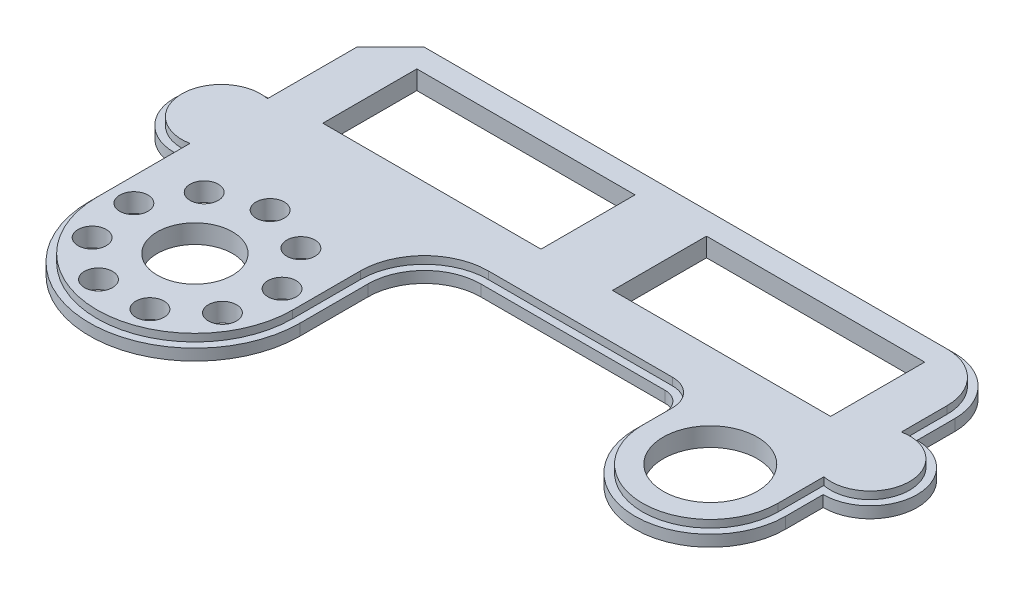
from build123d import *

# Parameters (mm, degrees)
SKETCH1_R           = 15.875
SKETCH1_R_2         = 12.7
SKETCH1_W           = 73.66
SKETCH1_H           = 31.75
BOSS_EXTRUDE2_DEPTH = 6.35
CUT_EXTRUDE1_DEPTH  = 2.54
SKETCH3_R           = 4.7625
CUT_EXTRUDE2_DEPTH  = 7.35
CIRPATTERN1_COUNT   = 9


with BuildPart() as part:
    # Sketch1 → Boss-Extrude2 (new body)
    with BuildSketch(Plane(origin=(0, 0, 0), x_dir=(1, 0, 0), z_dir=(0, 1, 0))):
        with Locations((209.55, -47.625)):
            Circle(SKETCH1_R)
        with Locations((0, -57.15)):
            Circle(SKETCH1_R)
        with BuildLine():
            Line((209.55, -76.2), (209.55, -19.05))
            ThreePointArc((209.55, -19.05), (203.970384182, -5.579615818), (190.5, 0))
            Line((190.5, 0), (12.7, 0))
            Line((12.7, 0), (0, -12.7))
            Line((0, -12.7), (0, -101.6))
            ThreePointArc((0, -101.6), (35.56, -137.16), (71.12, -101.6))
            Line((71.12, -101.6), (71.12, -78.74))
            ThreePointArc((71.12, -78.74), (76.699615818, -65.269615818), (90.17, -59.69))
            Line((90.17, -59.69), (152.4, -59.69))
            ThreePointArc((152.4, -59.69), (156.890128061, -61.549871939), (158.75, -66.04))
            Line((158.75, -66.04), (158.75, -76.2))
            ThreePointArc((158.75, -76.2), (184.15, -101.6), (209.55, -76.2))
        make_face()
        with Locations((35.56, -101.6)):
            Circle(SKETCH1_R_2, mode=Mode.SUBTRACT)
        with Locations((184.15, -76.2)):
            Circle(SKETCH1_R, mode=Mode.SUBTRACT)
        with Locations((153.67, -26.035)):
            Rectangle(SKETCH1_W, SKETCH1_H, mode=Mode.SUBTRACT)
        with Locations((55.88, -26.035)):
            Rectangle(SKETCH1_W, SKETCH1_H, mode=Mode.SUBTRACT)
        with BuildLine():
            ThreePointArc((15.875, -57.15), (11.225320151, -45.924679849), (0, -41.275))
            Line((0, -41.275), (0, -73.025))
            ThreePointArc((0, -73.025), (11.225320151, -68.375320151), (15.875, -57.15))
        make_face()
        with BuildLine():
            Line((0, -73.025), (0, -41.275))
            ThreePointArc((0, -41.275), (-15.875, -57.15), (0, -73.025))
        make_face()
        with BuildLine():
            ThreePointArc((15.875, -57.15), (11.225320151, -45.924679849), (0, -41.275))
            Line((0, -41.275), (0, -73.025))
            ThreePointArc((0, -73.025), (11.225320151, -68.375320151), (15.875, -57.15))
        make_face()
        with BuildLine():
            Line((0, -73.025), (0, -41.275))
            ThreePointArc((0, -41.275), (-15.875, -57.15), (0, -73.025))
        make_face()
        with BuildLine():
            ThreePointArc((225.425, -47.625), (220.775320151, -36.399679849), (209.55, -31.75))
            Line((209.55, -31.75), (209.55, -63.5))
            ThreePointArc((209.55, -63.5), (220.775320151, -58.850320151), (225.425, -47.625))
        make_face()
        with BuildLine():
            Line((209.55, -63.5), (209.55, -31.75))
            ThreePointArc((209.55, -31.75), (193.675, -47.625), (209.55, -63.5))
        make_face()
        with BuildLine():
            ThreePointArc((225.425, -47.625), (220.775320151, -36.399679849), (209.55, -31.75))
            Line((209.55, -31.75), (209.55, -63.5))
            ThreePointArc((209.55, -63.5), (220.775320151, -58.850320151), (225.425, -47.625))
        make_face()
        with BuildLine():
            Line((209.55, -63.5), (209.55, -31.75))
            ThreePointArc((209.55, -31.75), (193.675, -47.625), (209.55, -63.5))
        make_face()
    extrude(amount=BOSS_EXTRUDE2_DEPTH)

    # Sketch2 → Cut-Extrude1 (cut)
    with BuildSketch(Plane(origin=(0, 6.35, 0), x_dir=(1, 0, 0), z_dir=(0, 1, 0))):
        with BuildLine():
            Line((209.55, -76.2), (209.55, -63.5))
            ThreePointArc((209.55, -63.5), (225.425, -47.625), (209.55, -31.75))
            Line((209.55, -31.75), (209.55, -19.05))
            ThreePointArc((209.55, -19.05), (203.970384182, -5.579615818), (190.5, 0))
            Line((190.5, 0), (12.7, 0))
            Line((12.7, 0), (0, -12.7))
            Line((0, -12.7), (0, -41.275))
            ThreePointArc((0, -41.275), (-15.875, -57.15), (0, -73.025))
            Line((0, -73.025), (0, -101.6))
            ThreePointArc((0, -101.6), (35.56, -137.16), (71.12, -101.6))
            Line((71.12, -101.6), (71.12, -78.74))
            ThreePointArc((71.12, -78.74), (76.699615818, -65.269615818), (90.17, -59.69))
            Line((90.17, -59.69), (152.4, -59.69))
            ThreePointArc((152.4, -59.69), (156.890128061, -61.549871939), (158.75, -66.04))
            Line((158.75, -66.04), (158.75, -76.2))
            ThreePointArc((158.75, -76.2), (184.15, -101.6), (209.55, -76.2))
        make_face()
        with BuildLine():
            Line((2.54, -13.752102448), (2.54, -44.059139639))
            ThreePointArc((2.54, -44.059139639), (-13.335, -57.15), (2.54, -70.240860361))
            Line((2.54, -70.240860361), (2.54, -101.6))
            ThreePointArc((2.54, -101.6), (35.56, -134.62), (68.58, -101.6))
            Line((68.58, -101.6), (68.58, -78.74))
            ThreePointArc((68.58, -78.74), (74.903564594, -63.473564594), (90.17, -57.15))
            Line((90.17, -57.15), (152.4, -57.15))
            ThreePointArc((152.4, -57.15), (158.686179285, -59.753820715), (161.29, -66.04))
            Line((161.29, -66.04), (161.29, -76.2))
            ThreePointArc((161.29, -76.2), (184.15, -99.06), (207.01, -76.2))
            Line((207.01, -76.2), (207.01, -60.715860361))
            ThreePointArc((207.01, -60.715860361), (222.885, -47.625), (207.01, -34.534139639))
            Line((207.01, -34.534139639), (207.01, -19.05))
            ThreePointArc((207.01, -19.05), (202.174332957, -7.375667043), (190.5, -2.54))
            Line((190.5, -2.54), (13.752102448, -2.54))
            Line((13.752102448, -2.54), (2.54, -13.752102448))
        make_face(mode=Mode.SUBTRACT)
    extrude(amount=-CUT_EXTRUDE1_DEPTH, mode=Mode.SUBTRACT)

    # Sketch3 → Cut-Extrude2 (cut, through all)
    with BuildSketch(Plane(origin=(0, 6.35, 0), x_dir=(1, 0, 0), z_dir=(0, 1, 0))):
        with Locations((35.56, -76.2)):
            Circle(SKETCH3_R)
    cut_extrude2 = extrude(amount=-CUT_EXTRUDE2_DEPTH, mode=Mode.SUBTRACT)

    # CirPattern1: Cut-Extrude2 ×9 about axis
    cirpattern1_axis = Axis((35.56, 0, 101.6), (0, 1, 0))
    for i in range(1, CIRPATTERN1_COUNT):
        add(cut_extrude2.rotate(cirpattern1_axis, i * 360 / CIRPATTERN1_COUNT), mode=Mode.SUBTRACT)


solid = part.part
